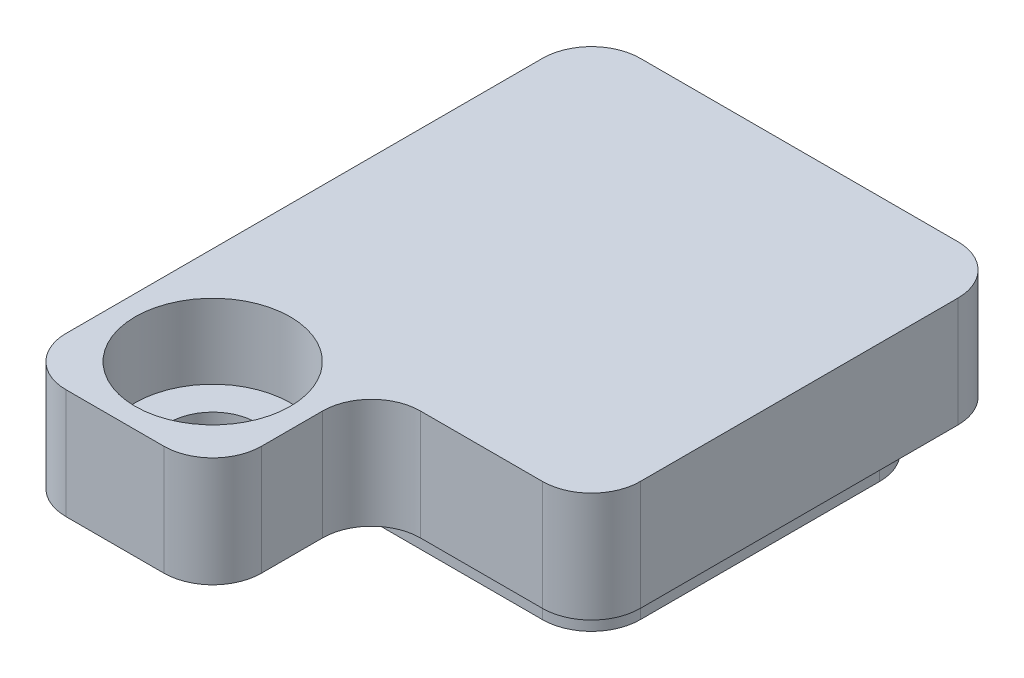
from build123d import *

# Parameters (mm, degrees)
SKETCH1_W                                      = 8.5
SKETCH1_H                                      = 8.5
EXTRUDE1_DEPTH                                 = 2.25
SKETCH7_W                                      = 6.9
SKETCH7_H                                      = 6.9
EXTRUDE5_DEPTH                                 = 1
SKETCH3_W                                      = 4
SKETCH3_H                                      = 2.25
EXTRUDE3_DEPTH                                 = 3.25
CBORE_FOR_0_SOCKET_HEAD_CAP_SCREW1_D           = 1.778
CBORE_FOR_0_SOCKET_HEAD_CAP_SCREW1_CBORE_D     = 3.175
CBORE_FOR_0_SOCKET_HEAD_CAP_SCREW1_CBORE_DEPTH = 1.524
FILLET2_R                                      = 1


with BuildPart() as part:
    # Sketch1 → Extrude1 (new body)
    with BuildSketch(Plane(origin=(0, 0, 0), x_dir=(1, 0, 0), z_dir=(0, 1, 0))):
        Rectangle(SKETCH1_W, SKETCH1_H)
    extrude(amount=EXTRUDE1_DEPTH)

    # Sketch7 → Extrude5 (add)
    with BuildSketch(Plane.XZ):
        Rectangle(SKETCH7_W, SKETCH7_H)
    extrude(amount=EXTRUDE5_DEPTH)

    # Sketch3 → Extrude3 (add)
    with BuildSketch(Plane.XY.offset(4.25)):
        with Locations((-2.25, 1.125)):
            Rectangle(SKETCH3_W, SKETCH3_H)
    extrude(amount=EXTRUDE3_DEPTH)

    # CBORE for #0 Socket Head Cap Screw1 (through all)
    with Locations(Plane(origin=(-2.25, 2.25, 5.5), x_dir=(0, 0, 1), z_dir=(0, 1, 0))):
        with Locations((0, 0)):
            CounterBoreHole(CBORE_FOR_0_SOCKET_HEAD_CAP_SCREW1_D / 2, CBORE_FOR_0_SOCKET_HEAD_CAP_SCREW1_CBORE_D / 2, CBORE_FOR_0_SOCKET_HEAD_CAP_SCREW1_CBORE_DEPTH)

    # Fillet2
    fillet2_edges = [part.edges().sort_by_distance(p)[0] for p in [
        (-3.45, -0.5, -3.45),
        (-4.25, 1.125, -4.25),
        (-3.45, -0.5, 3.45),
        (3.45, -0.5, -3.45),
        (3.45, -0.5, 3.45),
        (4.25, 1.125, -4.25),
        (4.25, 1.125, 4.25),
        (-4.25, 1.125, 7.5),
        (-0.25, 1.125, 7.5),
        (-0.25, 1.125, 4.25),
    ]]
    fillet(fillet2_edges, radius=FILLET2_R)


solid = part.part
